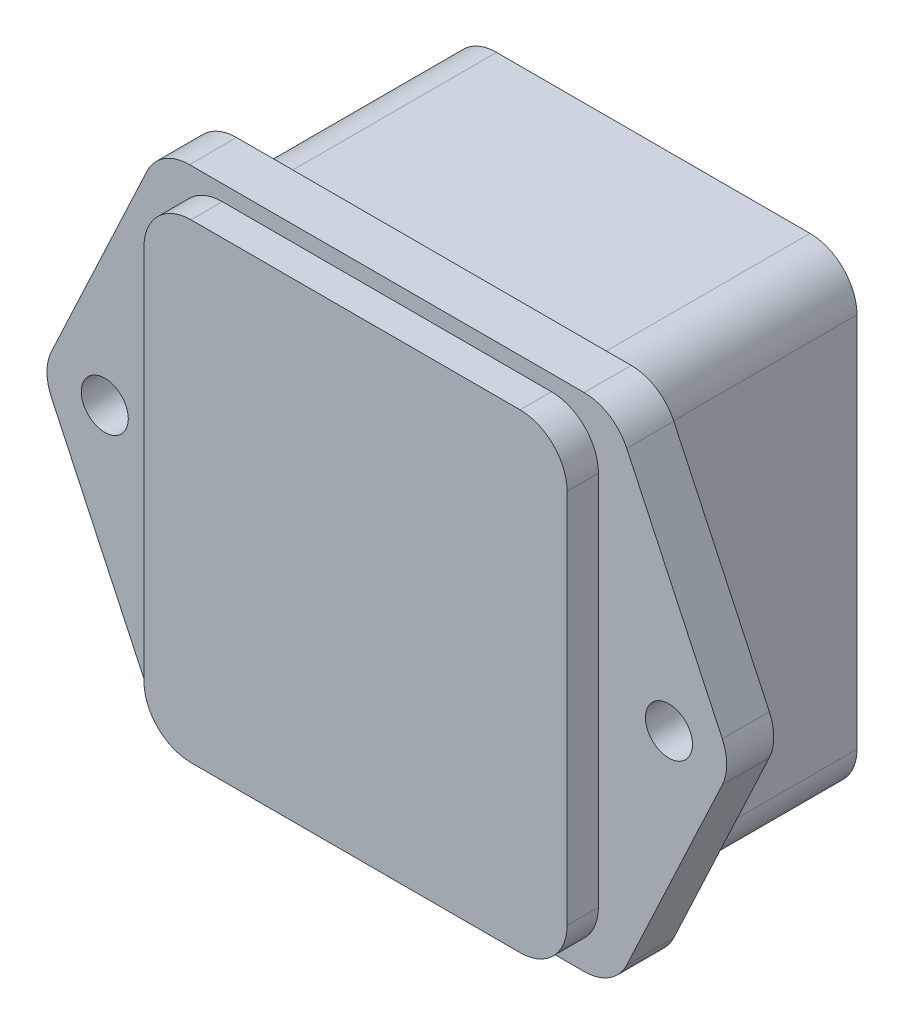
from build123d import *

# Parameters (mm, degrees)
SKETCH1_R           = 1.5
BOSS_EXTRUDE1_DEPTH = 3
SKETCH4_W           = 27
SKETCH4_H           = 30
BOSS_EXTRUDE2_DEPTH = 2
SKETCH5_W           = 26
SKETCH5_H           = 30
BOSS_EXTRUDE3_DEPTH = 14
FILLET1_R           = 3


with BuildPart() as part:
    # Sketch1 → Boss-Extrude1 (new body)
    with BuildSketch(Plane.XY):
        Polygon((-14.5, 16), (14.5, 16), (22, 0), (14.5, -16), (-14.5, -16), (-22, 0), align=None)
        with Locations((-18, 0)):
            Circle(SKETCH1_R, mode=Mode.SUBTRACT)
        with Locations((18, 0)):
            Circle(SKETCH1_R, mode=Mode.SUBTRACT)
    extrude(amount=BOSS_EXTRUDE1_DEPTH)

    # Sketch4 → Boss-Extrude2 (add)
    with BuildSketch(Plane.XY.offset(3)):
        Rectangle(SKETCH4_W, SKETCH4_H)
    extrude(amount=BOSS_EXTRUDE2_DEPTH)

    # Sketch5 → Boss-Extrude3 (add)
    with BuildSketch(Plane(origin=(0, 0, 0), x_dir=(-1, 0, 0), z_dir=(0, 0, -1))):
        Rectangle(SKETCH5_W, SKETCH5_H)
    extrude(amount=BOSS_EXTRUDE3_DEPTH)

    # Fillet1
    fillet1_edges = [part.edges().sort_by_distance(p)[0] for p in [
        (-14.5, 16, 1.5),
        (14.5, 16, 1.5),
        (22, 0, 1.5),
        (14.5, -16, 1.5),
        (-14.5, -16, 1.5),
        (-22, 0, 1.5),
        (13.5, -15, 4),
        (13.5, 15, 4),
        (-13.5, 15, 4),
        (-13.5, -15, 4),
        (-13, -15, -7),
        (-13, 15, -7),
        (13, 15, -7),
        (13, -15, -7),
    ]]
    fillet(fillet1_edges, radius=FILLET1_R)


solid = part.part
